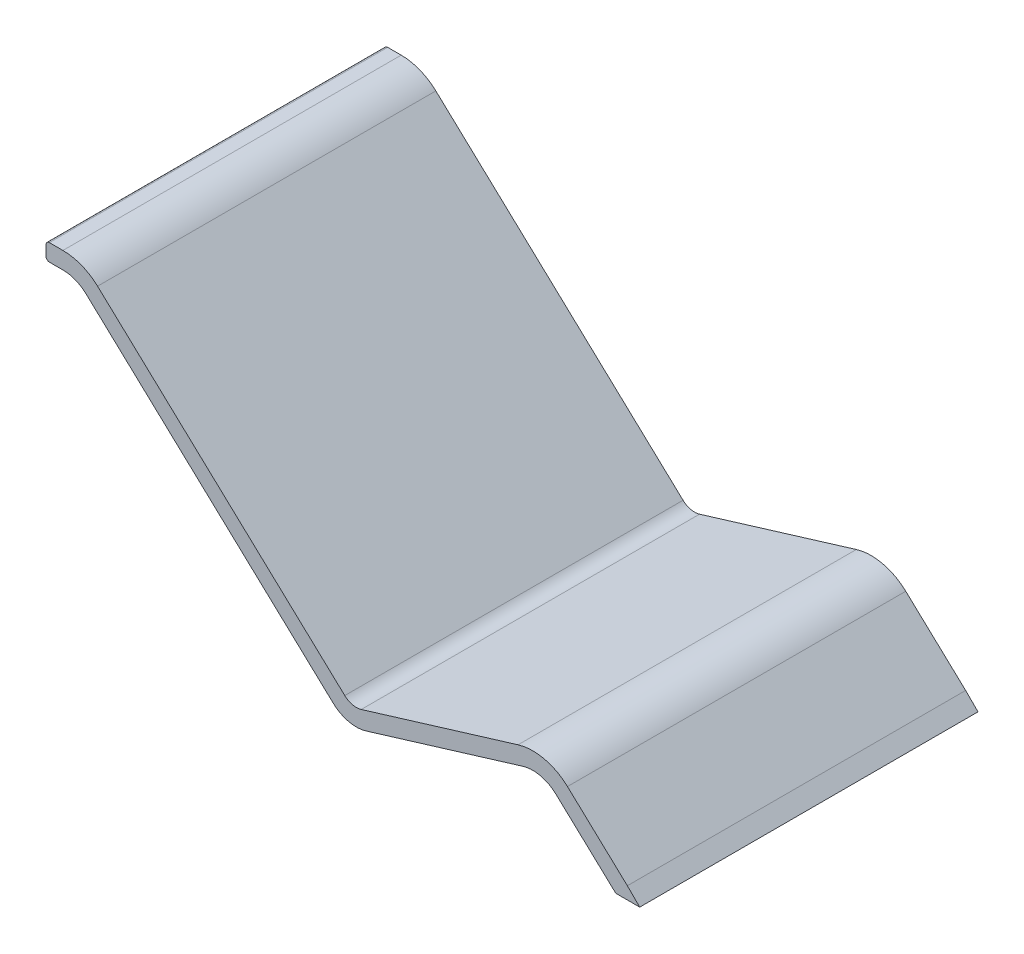
from build123d import *

# Parameters (mm, degrees)
EXTRUDE_1_DEPTH = 100


with BuildPart() as part:
    # 草图1 → 凸台-拉伸1 (new body)
    with BuildSketch(Plane.XY):
        with BuildLine():
            Line((-4.219496526, 3.940708363), (-77.303320181, 72.195779383))
            ThreePointArc((-77.303320181, 72.195779383), (-80.46030058, 74.190187557), (-84.128827283, 74.887397018))
            Line((-84.128827283, 74.887397018), (-88.128827283, 74.887397018))
            ThreePointArc((-88.128827283, 74.887397018), (-88.835934064, 75.180290236), (-89.128827283, 75.887397018))
            Line((-89.128827283, 75.887397018), (-89.128827283, 78.887397018))
            ThreePointArc((-89.128827283, 78.887397018), (-88.835934064, 79.594503799), (-88.128827283, 79.887397018))
            Line((-88.128827283, 79.887397018), (-84.128827283, 79.887397018))
            ThreePointArc((-84.128827283, 79.887397018), (-78.626037228, 78.841582827), (-73.89056663, 75.849970566))
            Line((-73.89056663, 75.849970566), (-0.806742975, 7.594899545))
            ThreePointArc((-0.806742975, 7.594899545), (1.477574895, 6.378091558), (4.064256195, 6.466463865))
            Line((4.064256195, 6.466463865), (50.410774928, 20.59773729))
            ThreePointArc((50.410774928, 20.59773729), (58.170818827, 20.86285421), (65.023772438, 17.212430248))
            Line((65.023772438, 17.212430248), (82.729423008, 0.676617305))
            Line((82.729423008, 0.676617305), (86.383614191, -2.977573878))
            Line((86.383614191, -2.977573878), (79.316669457, -2.977573878))
            Line((79.316669457, -2.977573878), (61.611018887, 13.558239066))
            ThreePointArc((61.611018887, 13.558239066), (57.042383146, 15.99185504), (51.869020547, 15.815110427))
            Line((51.869020547, 15.815110427), (5.522501814, 1.683837001))
            ThreePointArc((5.522501814, 1.683837001), (0.349139215, 1.507092388), (-4.219496526, 3.940708363))
        make_face()
    extrude(amount=EXTRUDE_1_DEPTH)


solid = part.part
